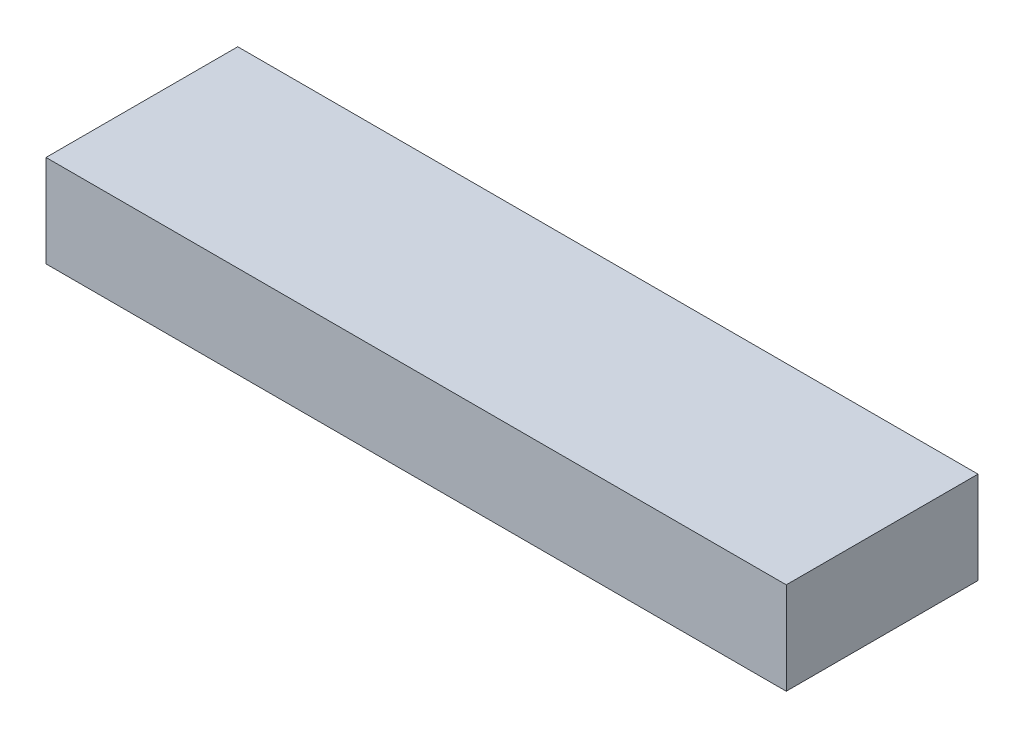
from build123d import *

# Parameters (mm, degrees)
SKETCH1_W           = 80.3
SKETCH1_H           = 20.8
BOSS_EXTRUDE1_DEPTH = 10


with BuildPart() as part:
    # Sketch1 → Boss-Extrude1 (new body)
    with BuildSketch(Plane(origin=(0, 0, 0), x_dir=(1, 0, 0), z_dir=(0, 1, 0))):
        with Locations((-49.024835526, 20.888576935)):
            Rectangle(SKETCH1_W, SKETCH1_H)
    extrude(amount=BOSS_EXTRUDE1_DEPTH)


solid = part.part
